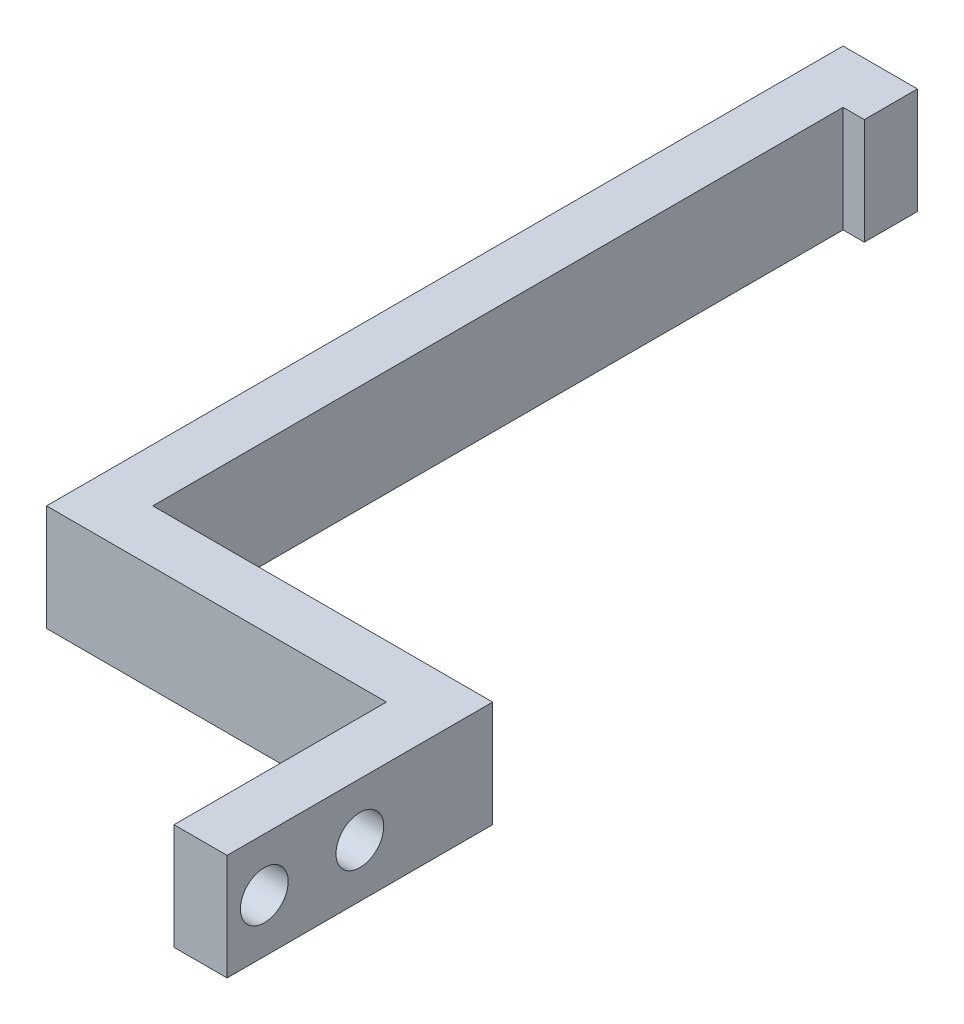
from build123d import *

# Parameters (mm, degrees)
BOSS_EXTRUDE1_DEPTH = 10
SKETCH3_R           = 2.25
CUT_EXTRUDE1_DEPTH  = 38


with BuildPart() as part:
    # Sketch2 → Boss-Extrude1 (new body)
    with BuildSketch(Plane(origin=(0, 0, 0), x_dir=(1, 0, 0), z_dir=(0, 1, 0))):
        Polygon((-5, 0), (0, 0), (0, 25), (-32, 25), (-32, 90), (-30, 90), (-30, 95), (-37, 95), (-37, 20), (-5, 20), align=None)
    extrude(amount=BOSS_EXTRUDE1_DEPTH)

    # Sketch3 → Cut-Extrude1 (cut, through all)
    with BuildSketch(Plane(origin=(0, 0, 0), x_dir=(0, 0, -1), z_dir=(1, 0, 0))):
        with Locations((3.5, 5)):
            Circle(SKETCH3_R)
        with Locations((12.5, 5)):
            Circle(SKETCH3_R)
    extrude(amount=-CUT_EXTRUDE1_DEPTH, mode=Mode.SUBTRACT)


solid = part.part
